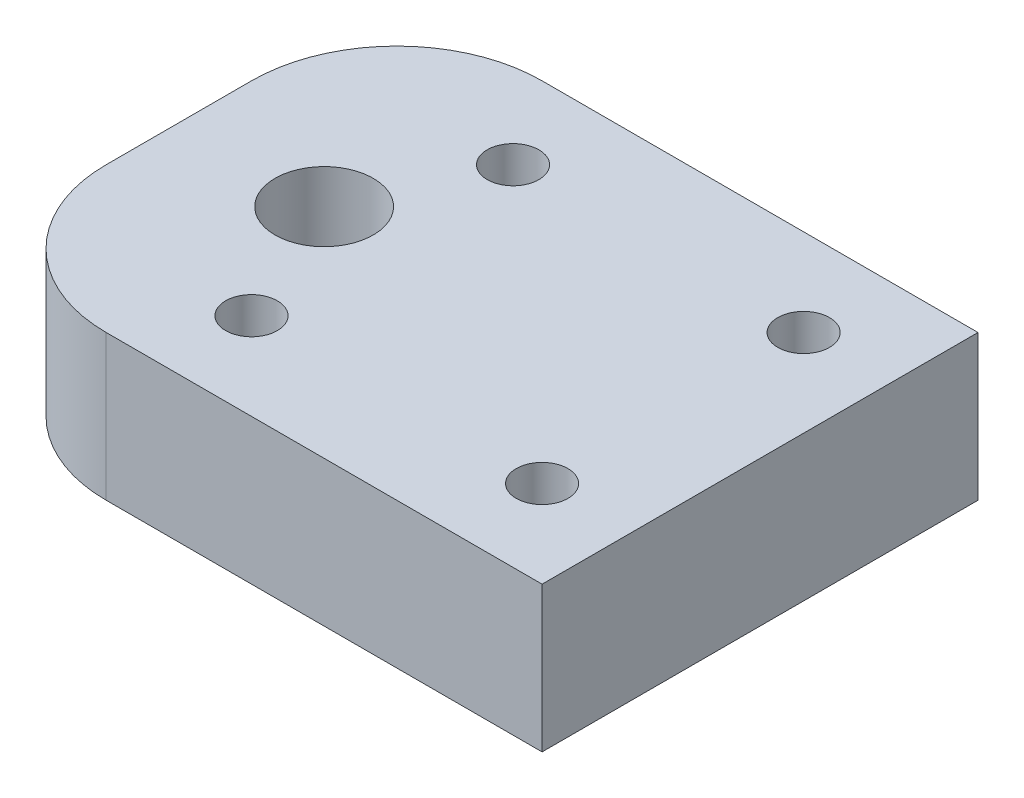
from build123d import *

# Parameters (mm, degrees)
SKETCH1_W                 = 25.4
SKETCH1_H                 = 19.05
SKETCH1_R                 = 2.1463
BOSS_EXTRUDE1_DEPTH       = 6.35
F_4_40_TAPPED_HOLE1_D     = 2.2606
F_4_40_TAPPED_HOLE1_DEPTH = 7.5946
F_4_40_TAPPED_HOLE1_TIP   = 0.679152758
FILLET1_R                 = 6.35


with BuildPart() as part:
    # Sketch1 → Boss-Extrude1 (new body)
    with BuildSketch(Plane(origin=(0, 0, 0), x_dir=(1, 0, 0), z_dir=(0, 1, 0))):
        with Locations((6.35, 0)):
            Rectangle(SKETCH1_W, SKETCH1_H)
        Circle(SKETCH1_R, mode=Mode.SUBTRACT)
    extrude(amount=BOSS_EXTRUDE1_DEPTH)

    # #4-40 Tapped Hole1
    with Locations(Plane(origin=(0, 6.35, 0), x_dir=(1, 0, 0), z_dir=(0, 1, 0))):
        with Locations((2.54, 5.715), (15.24, -5.715), (2.54, -5.715), (15.24, 5.715)):
            Hole(F_4_40_TAPPED_HOLE1_D / 2, depth=F_4_40_TAPPED_HOLE1_DEPTH)
            with Locations((0, 0, -(F_4_40_TAPPED_HOLE1_DEPTH + F_4_40_TAPPED_HOLE1_TIP / 2))):  # 118° drill point
                Cone(0, F_4_40_TAPPED_HOLE1_D / 2, F_4_40_TAPPED_HOLE1_TIP, mode=Mode.SUBTRACT)

    # Fillet1
    fillet1_edges = [part.edges().sort_by_distance(p)[0] for p in [
        (-6.35, 3.175, -9.525),
        (-6.35, 3.175, 9.525),
    ]]
    fillet(fillet1_edges, radius=FILLET1_R)


solid = part.part
